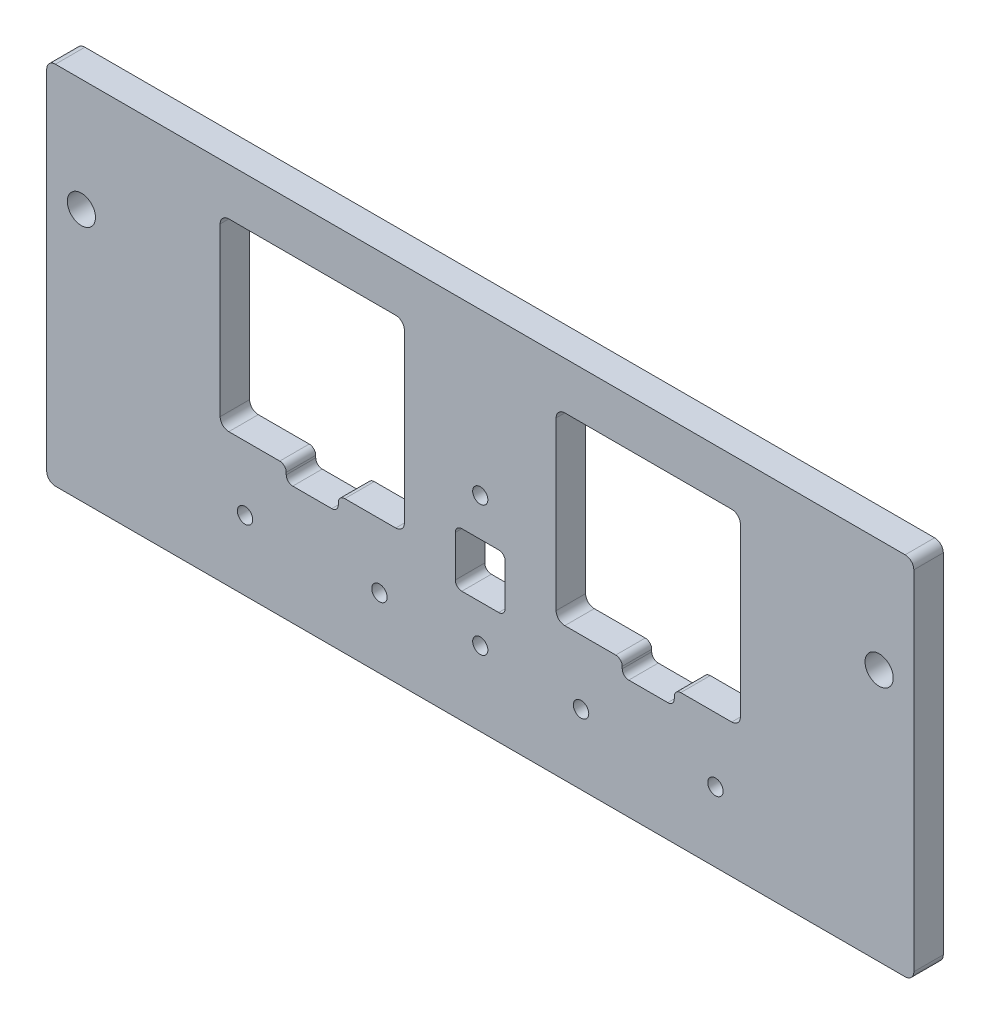
from build123d import *

# Parameters (mm, degrees)
SKETCH1_W            = 200
SKETCH1_H            = 84.3
BOSS_EXTRUDE1_DEPTH  = 6.8
SKETCH2_R            = 3.25
CUT_EXTRUDE1_DEPTH   = 6.8
FILLET1_R            = 2
SKETCH3_R            = 1.775
SKETCH3_W            = 42.5
SKETCH3_H            = 42.5
CUT_EXTRUDE2_DEPTH   = 7.8
FILLET2_R            = 2
SKETCH4_W            = 12
SKETCH4_H            = 7
CUT_EXTRUDE3_DEPTH   = 7.8
FILLET3_R            = 1.5
SKETCH5_R            = 1.75
SKETCH5_W            = 11.5
SKETCH5_H            = 12.5
CUT_EXTRUDE4_DEPTH   = 7.8
FILLET4_R            = 1.5
FILLET2_OF_MIRROR2_R = 2
FILLET3_OF_MIRROR2_R = 1.5


with BuildPart() as part:
    # Sketch1 → Boss-Extrude1 (new body)
    with BuildSketch(Plane.XY):
        Rectangle(SKETCH1_W, SKETCH1_H)
    extrude(amount=BOSS_EXTRUDE1_DEPTH)

    # Sketch2 → Cut-Extrude1 (cut)
    with BuildSketch(Plane.XY.offset(6.8)):
        with Locations((-92, 16.15)):
            Circle(SKETCH2_R)
        with Locations((92, 16.15)):
            Circle(SKETCH2_R)
    extrude(amount=-CUT_EXTRUDE1_DEPTH, mode=Mode.SUBTRACT)

    # Fillet1
    fillet1_edges = [part.edges().sort_by_distance(p)[0] for p in [
        (-100, 42.15, 3.4),
        (100, 42.15, 3.4),
        (100, -42.15, 3.4),
        (-100, -42.15, 3.4),
    ]]
    fillet(fillet1_edges, radius=FILLET1_R)

    # Sketch3 → Cut-Extrude2 (cut, through all)
    with BuildSketch(Plane.XY.offset(6.8)):
        with Locations((23.25, -26.082)):
            Circle(SKETCH3_R)
        with Locations((54.25, -26.082)):
            Circle(SKETCH3_R)
        with Locations((38.75, 10)):
            Rectangle(SKETCH3_W, SKETCH3_H)
    cut_extrude2 = extrude(amount=-CUT_EXTRUDE2_DEPTH, mode=Mode.SUBTRACT)

    # Fillet2
    fillet2_edges = [part.edges().sort_by_distance(p)[0] for p in [
        (17.5, -11.25, 3.4),
        (17.5, 31.25, 3.4),
        (60, 31.25, 3.4),
        (60, -11.25, 3.4),
    ]]
    fillet(fillet2_edges, radius=FILLET2_R)

    # Sketch4 → Cut-Extrude3 (cut, through all)
    with BuildSketch(Plane.XY.offset(6.8)):
        with Locations((38.75, -11.25)):
            Rectangle(SKETCH4_W, SKETCH4_H)
    cut_extrude3 = extrude(amount=-CUT_EXTRUDE3_DEPTH, mode=Mode.SUBTRACT)

    # Fillet3
    fillet3_edges = [part.edges().sort_by_distance(p)[0] for p in [
        (44.75, -11.25, 3.4),
        (32.75, -11.25, 3.4),
        (32.75, -14.75, 3.4),
        (44.75, -14.75, 3.4),
    ]]
    fillet(fillet3_edges, radius=FILLET3_R)

    # Sketch5 → Cut-Extrude4 (cut, through all)
    with BuildSketch(Plane.XY.offset(6.8)):
        with Locations((0, -25)):
            Circle(SKETCH5_R)
        with Locations((0, 5)):
            Circle(SKETCH5_R)
        with Locations((0, -10)):
            Rectangle(SKETCH5_W, SKETCH5_H)
    extrude(amount=-CUT_EXTRUDE4_DEPTH, mode=Mode.SUBTRACT)

    # Fillet4
    fillet4_edges = [part.edges().sort_by_distance(p)[0] for p in [
        (-5.75, -16.25, 3.4),
        (-5.75, -3.75, 3.4),
        (5.75, -3.75, 3.4),
        (5.75, -16.25, 3.4),
    ]]
    fillet(fillet4_edges, radius=FILLET4_R)

    # Mirror2: Cut-Extrude2, Cut-Extrude3 across plane
    add(cut_extrude2.mirror(Plane(origin=(0, 0, 0), x_dir=(0, 0, 1), z_dir=(1, 0, 0))), mode=Mode.SUBTRACT)
    add(cut_extrude3.mirror(Plane(origin=(0, 0, 0), x_dir=(0, 0, 1), z_dir=(1, 0, 0))), mode=Mode.SUBTRACT)

    # Fillet2 of Mirror2
    fillet2_of_mirror2_edges = [part.edges().sort_by_distance(p)[0] for p in [
        (-17.5, -11.25, 3.4),
        (-17.5, 31.25, 3.4),
        (-60, 31.25, 3.4),
        (-60, -11.25, 3.4),
    ]]
    fillet(fillet2_of_mirror2_edges, radius=FILLET2_OF_MIRROR2_R)

    # Fillet3 of Mirror2
    fillet3_of_mirror2_edges = [part.edges().sort_by_distance(p)[0] for p in [
        (-44.75, -11.25, 3.4),
        (-32.75, -11.25, 3.4),
        (-32.75, -14.75, 3.4),
        (-44.75, -14.75, 3.4),
    ]]
    fillet(fillet3_of_mirror2_edges, radius=FILLET3_OF_MIRROR2_R)


solid = part.part
